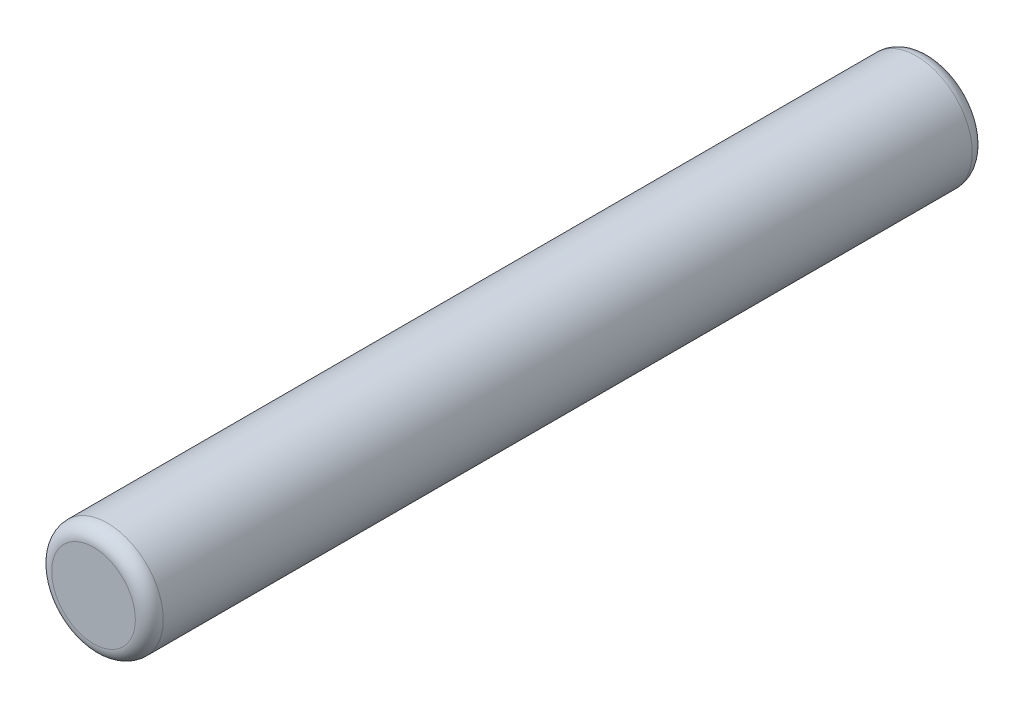
from build123d import *

# Parameters (mm, degrees)
SKETCH1_R           = 2
BOSS_EXTRUDE1_DEPTH = 15
FILLET2_R           = 0.5


with BuildPart() as part:
    # Sketch1 → Boss-Extrude1 (new body, symmetric)
    with BuildSketch(Plane.XY):
        Circle(SKETCH1_R)
    extrude(amount=BOSS_EXTRUDE1_DEPTH, both=True)

    # Fillet2
    fillet2_edges = [part.edges().sort_by_distance(p)[0] for p in [
        (-2, 0, -15),
        (-2, 0, 15),
    ]]
    fillet(fillet2_edges, radius=FILLET2_R)


solid = part.part
